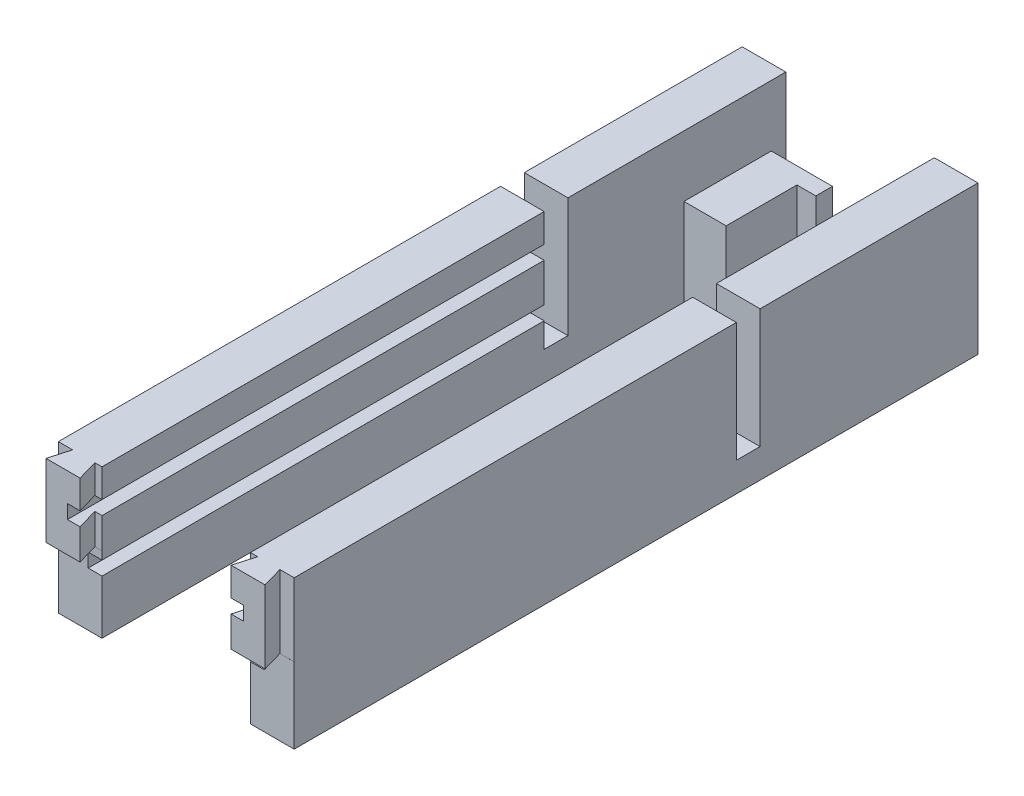
from build123d import *

# Parameters (mm, degrees)
SKETCH1_W           = 242
SKETCH1_H           = 51
BOSS_EXTRUDE1_DEPTH = 15
SKETCH26_W          = 30
SKETCH26_H          = 30
BOSS_EXTRUDE3_DEPTH = 29.5
SKETCH28_W          = 15
SKETCH28_H          = 9.75
BOSS_EXTRUDE5_DEPTH = 4.5
SKETCH29_W          = 5.7
SKETCH29_H          = 20
BOSS_EXTRUDE6_DEPTH = 6.5
CUT_EXTRUDE8_DEPTH  = 25
SKETCH13_W          = 15
SKETCH13_H          = 7.11
CUT_EXTRUDE9_DEPTH  = 26
SKETCH17_W          = 15
SKETCH17_H          = 8.15
CUT_EXTRUDE10_DEPTH = 41
SKETCH7_W           = 4.75
SKETCH7_H           = 4.75
CUT_EXTRUDE5_DEPTH  = 165


with BuildPart() as part:
    # Sketch1 → Boss-Extrude1 (new body)
    with BuildSketch(Plane(origin=(0, 0, 0), x_dir=(0, 0, -1), z_dir=(1, 0, 0))):
        with Locations((56.437921078, 5.057266603)):
            Rectangle(SKETCH1_W, SKETCH1_H)
    extrude(amount=BOSS_EXTRUDE1_DEPTH)

    # Sketch26 → Boss-Extrude3 (add)
    with BuildSketch(Plane.ZY):
        with Locations((-157.437921078, -5.442733397)):
            Rectangle(SKETCH26_W, SKETCH26_H)
    extrude(amount=-BOSS_EXTRUDE3_DEPTH)

    # Sketch28 → Boss-Extrude5 (add)
    with BuildSketch(Plane(origin=(29.5, 0, 0), x_dir=(0, 0, -1), z_dir=(1, 0, 0))):
        with Locations((154.541661602, -15.567733397)):
            Rectangle(SKETCH28_W, SKETCH28_H)
    extrude(amount=BOSS_EXTRUDE5_DEPTH)

    # Sketch29 → Boss-Extrude6 (add)
    with BuildSketch(Plane(origin=(29.5, 0, 0), x_dir=(0, 0, -1), z_dir=(1, 0, 0))):
        with Locations((169.587921078, -0.442733397)):
            Rectangle(SKETCH29_W, SKETCH29_H)
    extrude(amount=BOSS_EXTRUDE6_DEPTH)

    # Sketch12 → Cut-Extrude8 (cut)
    with BuildSketch(Plane(origin=(0, 30.557266603, 0), x_dir=(1, 0, 0), z_dir=(0, 1, 0))):
        Polygon((0, -57.448742372), (4.909716433, -57.448742372), (2.87, -64.562078922), (0, -64.562078922), align=None)
        Polygon((15, -57.448742372), (15, -64.562078922), (14.57, -64.562078922), (12.530283567, -57.448742372), align=None)
    extrude(amount=-CUT_EXTRUDE8_DEPTH, mode=Mode.SUBTRACT)

    # Sketch13 → Cut-Extrude9 (cut)
    with BuildSketch(Plane.XZ.offset(20.442733397)):
        with Locations((7.5, 61.007078922)):
            Rectangle(SKETCH13_W, SKETCH13_H)
    extrude(amount=-CUT_EXTRUDE9_DEPTH, mode=Mode.SUBTRACT)

    # Sketch17 → Cut-Extrude10 (cut)
    with BuildSketch(Plane(origin=(0, 30.557266603, 0), x_dir=(1, 0, 0), z_dir=(0, 1, 0))):
        with Locations((7.5, 98.512921078)):
            Rectangle(SKETCH17_W, SKETCH17_H)
    extrude(amount=-CUT_EXTRUDE10_DEPTH, mode=Mode.SUBTRACT)

    # Sketch7 → Cut-Extrude5 (cut)
    with BuildSketch(Plane(origin=(0, 0, -94.437921078), x_dir=(-1, 0, 0), z_dir=(0, 0, -1))):
        with Locations((-12.625, 0.432266603)):
            Rectangle(SKETCH7_W, SKETCH7_H)
        with Locations((-12.625, 18.432266603)):
            Rectangle(SKETCH7_W, SKETCH7_H)
    extrude(amount=-CUT_EXTRUDE5_DEPTH, mode=Mode.SUBTRACT)


with BuildPart() as body_2:
    # Mirror4: mirrored copy
    add(part.part.mirror(Plane(origin=(40.5, 0, 0), x_dir=(0, 0, 1), z_dir=(1, 0, 0))))


solid = Compound([part.part, body_2.part])
